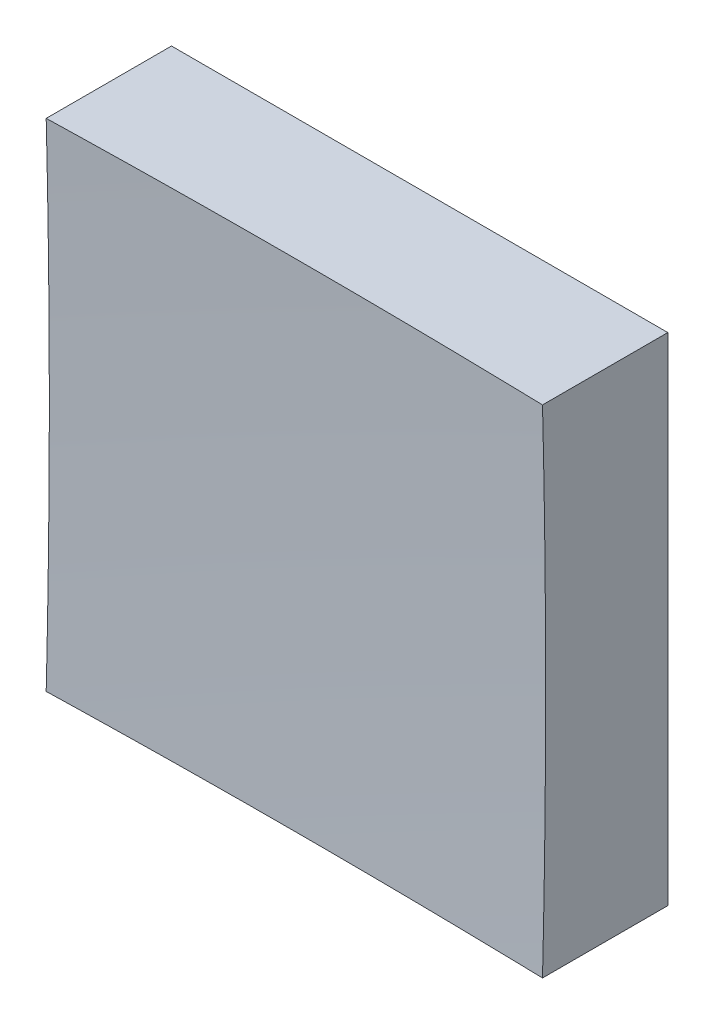
from build123d import *

# Parameters (mm, degrees)
SKETCH_1_W      = 25
SKETCH_1_H      = 25
EXTRUDE_1_DEPTH = 20


with BuildPart() as part:
    # 草图1 → 凸台-拉伸1 (new body)
    with BuildSketch(Plane.XY):
        Rectangle(SKETCH_1_W, SKETCH_1_H)
    extrude(amount=EXTRUDE_1_DEPTH)

    # 草图2 → 切除-旋转2 (revolve, cut)
    with BuildSketch(Plane(origin=(0, 0, 0), x_dir=(1, 0, 0), z_dir=(0, 1, 0))):
        with BuildLine():
            Line((487.422730906, -394.559067683), (0, -394.559067683))
            Line((0, -394.559067683), (0, -6))
            ThreePointArc((0, -6), (311.672531547, -115.026557067), (487.422730906, -394.559067683))
        make_face()
    revolve(axis=Axis((0, 0, 394.559067683), (0, 0, -1)), mode=Mode.SUBTRACT)


solid = part.part
